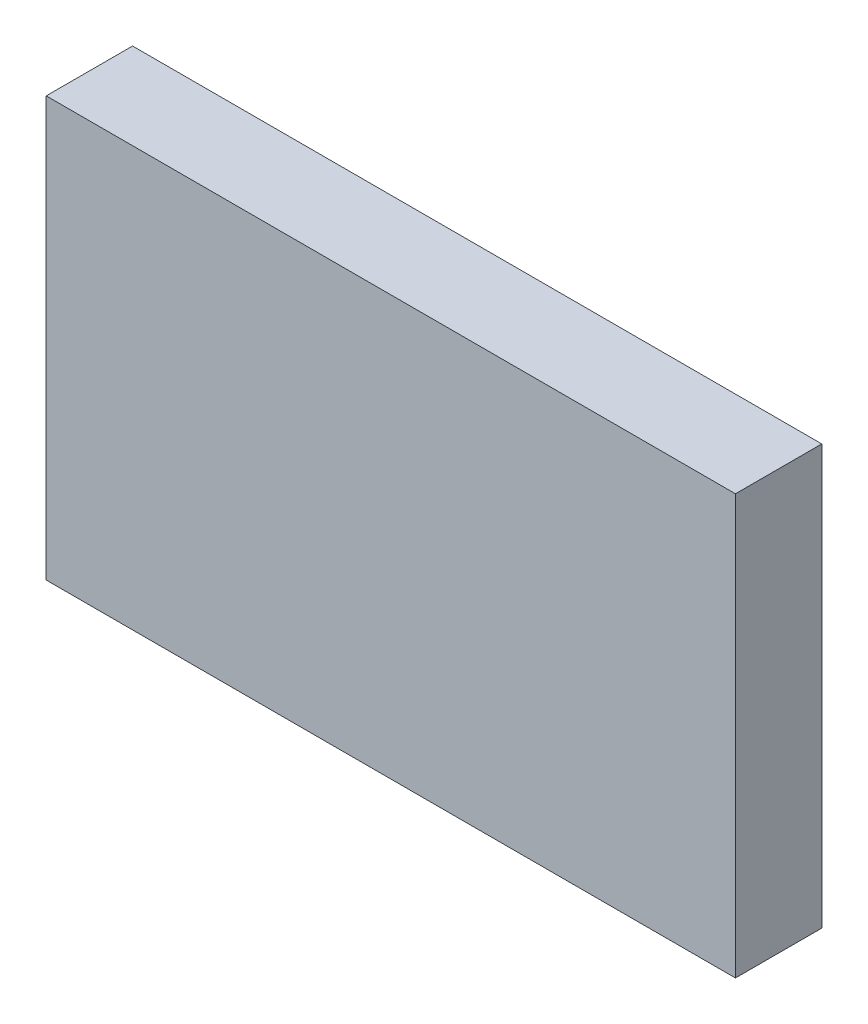
from build123d import *

# Parameters (mm, degrees)
SKETCH1_W           = 27.94
SKETCH1_H           = 3.5
BOSS_EXTRUDE1_DEPTH = 17


with BuildPart() as part:
    # Sketch1 → Boss-Extrude1 (new body)
    with BuildSketch(Plane(origin=(0, 0, 0), x_dir=(1, 0, 0), z_dir=(0, 1, 0))):
        Rectangle(SKETCH1_W, SKETCH1_H)
    extrude(amount=BOSS_EXTRUDE1_DEPTH)


solid = part.part
